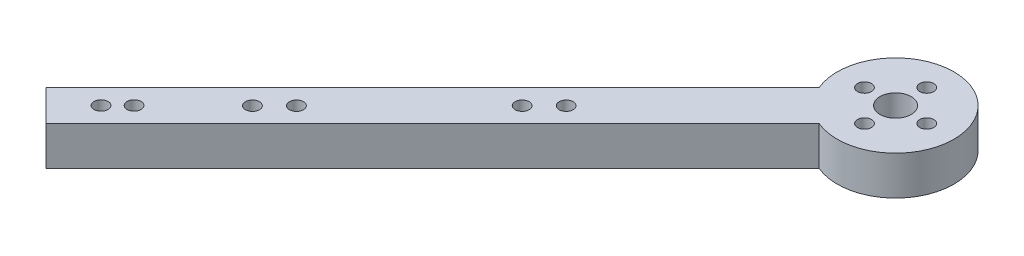
from build123d import *

# Parameters (mm, degrees)
SKETCH1_R           = 9.525
SKETCH1_R_2         = 2.54
SKETCH1_R_3         = 1.143
BOSS_EXTRUDE1_DEPTH = 6.35
BOSS_EXTRUDE2_DEPTH = 6.35
SKETCH4_R           = 1.143
CUT_EXTRUDE1_DEPTH  = 6.35


with BuildPart() as part:
    # Sketch1 → Boss-Extrude1 (new body)
    with BuildSketch(Plane(origin=(0, 0, 0), x_dir=(1, 0, 0), z_dir=(0, 1, 0))):
        Circle(SKETCH1_R)
        Circle(SKETCH1_R_2, mode=Mode.SUBTRACT)
        with Locations((-5.08, 0)):
            Circle(SKETCH1_R_3, mode=Mode.SUBTRACT)
        with Locations((0, 5.08)):
            Circle(SKETCH1_R_3, mode=Mode.SUBTRACT)
        with Locations((5.08, 0)):
            Circle(SKETCH1_R_3, mode=Mode.SUBTRACT)
        with Locations((0, -5.08)):
            Circle(SKETCH1_R_3, mode=Mode.SUBTRACT)
    extrude(amount=BOSS_EXTRUDE1_DEPTH)

    # Sketch3 → Boss-Extrude2 (add)
    with BuildSketch(Plane(origin=(0, 0, 0), x_dir=(1, 0, 0), z_dir=(0, 1, 0))):
        with BuildLine():
            ThreePointArc((-3.697885259, -8.777885259), (-6.735192091, -6.735192091), (-8.777885259, -3.697885259))
            Line((-8.777885259, -3.697885259), (-71.842048969, -66.762048969))
            Line((-71.842048969, -66.762048969), (-66.762048969, -71.842048969))
            Line((-66.762048969, -71.842048969), (-3.697885259, -8.777885259))
        make_face()
    extrude(amount=BOSS_EXTRUDE2_DEPTH)

    # Sketch4 → Cut-Extrude1 (cut)
    with BuildSketch(Plane(origin=(0, 6.35, 0), x_dir=(1, 0, 0), z_dir=(0, 1, 0))):
        with Locations((-64.821029526, -64.80281229)):
            Circle(SKETCH4_R)
        with Locations((-62.126952689, -62.108735454)):
            Circle(SKETCH4_R)
        with Locations((-52.438602593, -52.489659165)):
            Circle(SKETCH4_R)
        with Locations((-48.846500144, -48.897556717)):
            Circle(SKETCH4_R)
        with Locations((-30.436975096, -30.488031668)):
            Circle(SKETCH4_R)
        with Locations((-26.844872648, -26.89592922)):
            Circle(SKETCH4_R)
    extrude(amount=-CUT_EXTRUDE1_DEPTH, mode=Mode.SUBTRACT)


solid = part.part
